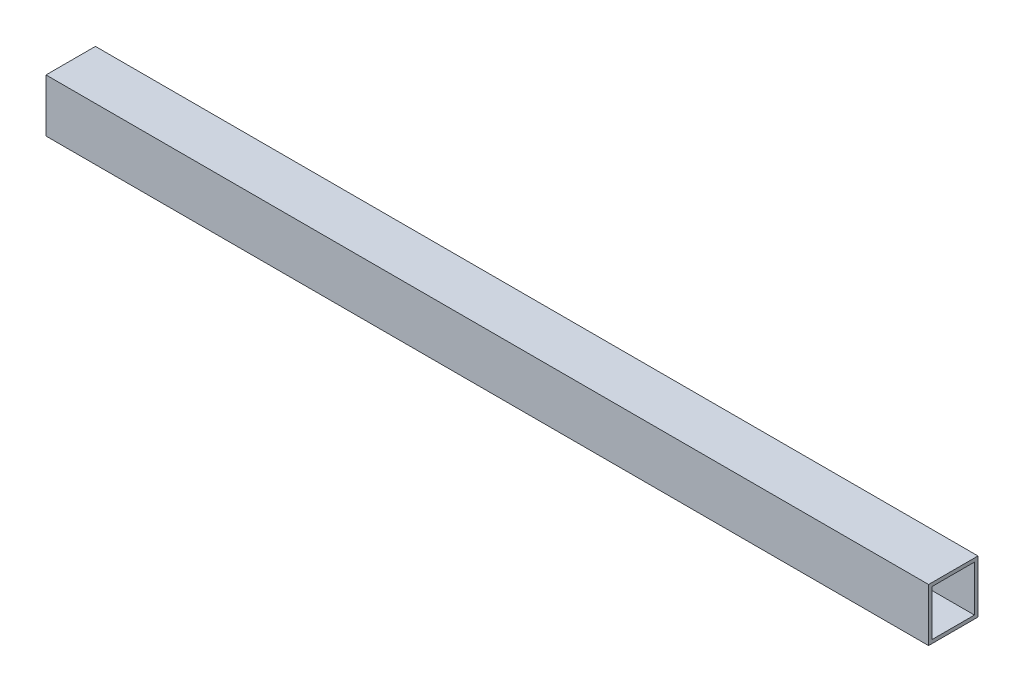
from build123d import *

# Parameters (mm, degrees)
SKETCH_2_W      = 70
SKETCH_2_H      = 75
SKETCH_2_W_2    = 60
SKETCH_2_H_2    = 65
EXTRUDE_1_DEPTH = 1250


with BuildPart() as part:
    # Эскиз2 → Вытянуть-Тонкостенный1 (new body)
    with BuildSketch(Plane(origin=(0, 0, 0), x_dir=(0, 0, -1), z_dir=(1, 0, 0))):
        Rectangle(SKETCH_2_W, SKETCH_2_H)
        Rectangle(SKETCH_2_W_2, SKETCH_2_H_2, mode=Mode.SUBTRACT)
    extrude(amount=EXTRUDE_1_DEPTH)


solid = part.part
